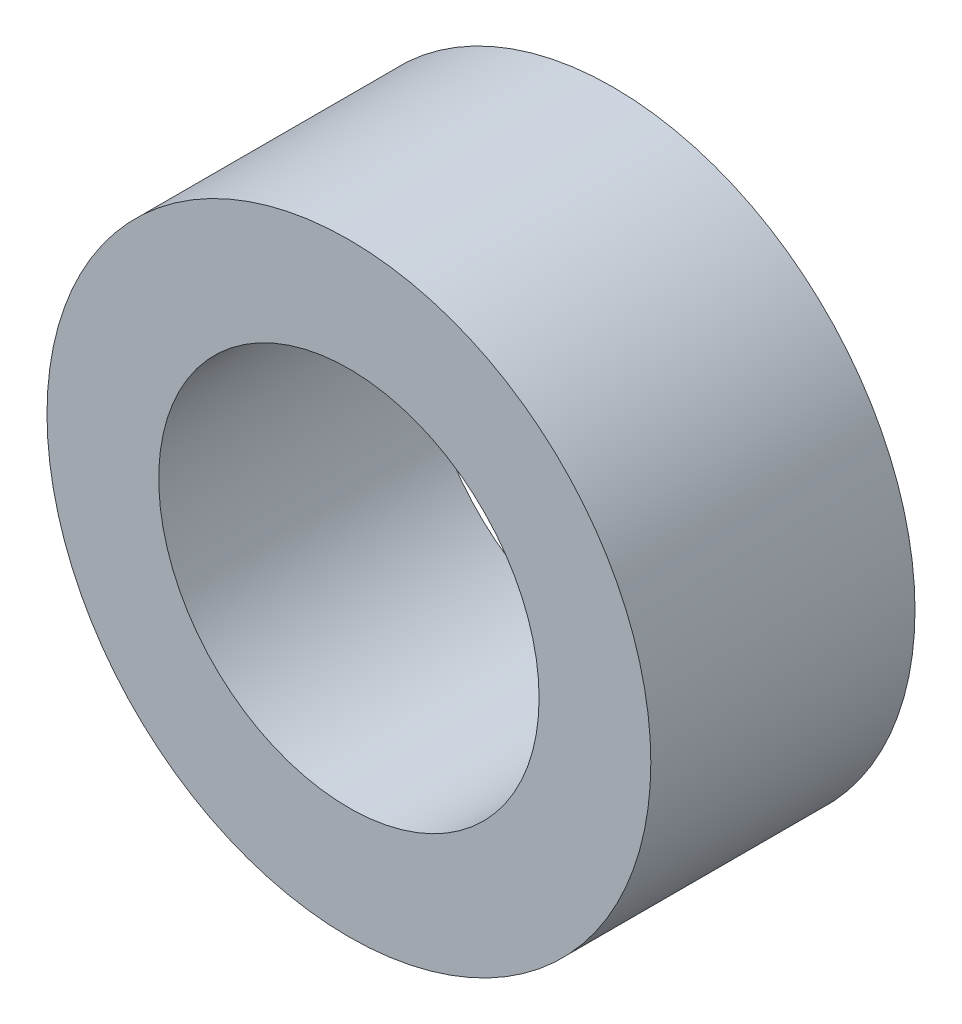
from build123d import *

# Parameters (mm, degrees)
SKETCH2_R           = 6.35
SKETCH2_R_2         = 4
BOSS_EXTRUDE1_DEPTH = 5.55625


with BuildPart() as part:
    # Sketch2 → Boss-Extrude1 (new body)
    with BuildSketch(Plane.XY.offset(4)):
        with Locations((216.050914922, 692.642443937)):
            Circle(SKETCH2_R)
        with Locations((216.050914922, 692.642443937)):
            Circle(SKETCH2_R_2, mode=Mode.SUBTRACT)
    extrude(amount=BOSS_EXTRUDE1_DEPTH)


solid = part.part
